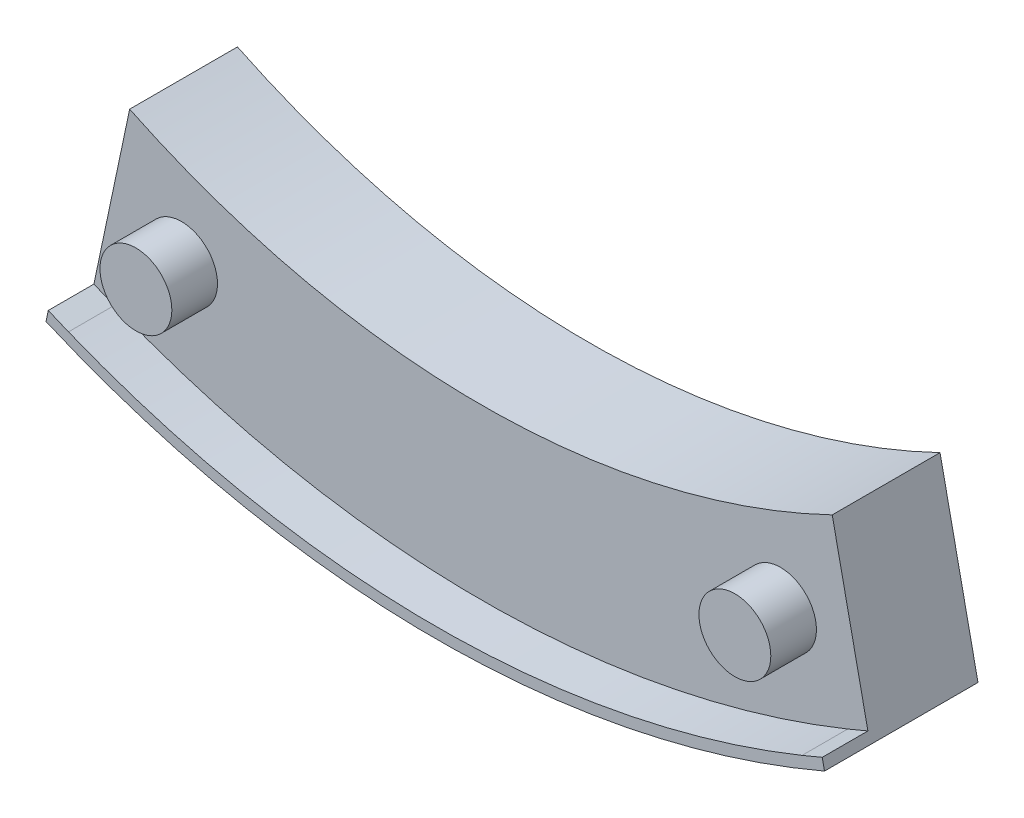
from build123d import *

# Parameters (mm, degrees)
SKETCH1_R           = 1.999999943
BOSS_EXTRUDE1_DEPTH = 6
SKETCH1_3_R         = 1.999999943
BOSS_EXTRUDE2_DEPTH = 8.54


with BuildPart() as part:
    # Sketch1 → Boss-Extrude1 (new body)
    with BuildSketch(Plane.XY):
        with BuildLine():
            Line((-19.553972123, -40.529522255), (-21.543248991, -49.954902644))
            Line((-21.543248991, -49.954902644), (-20.41822196, -50.425046499))
            ThreePointArc((-20.41822196, -50.425046499), (-10.404121129, -53.396800588), (-0.006635132, -54.399707743))
            ThreePointArc((-0.006635132, -54.399707743), (10.39066306, -53.396824107), (20.404594428, -50.42516399))
            Line((20.404594428, -50.42516399), (21.529621459, -49.955020135))
            Line((21.529621459, -49.955020135), (19.54391785, -40.534371527))
            ThreePointArc((19.54391785, -40.534371527), (-0.005581304, -44.999999654), (-19.553972123, -40.529522255))
        make_face()
        with Locations((-16.665975394, -46.501988883)):
            Circle(SKETCH1_R, mode=Mode.SUBTRACT)
        with Locations((16.665975394, -46.501988883)):
            Circle(SKETCH1_R, mode=Mode.SUBTRACT)
    extrude(amount=BOSS_EXTRUDE1_DEPTH)

    # Sketch1_3 → Boss-Extrude2 (add)
    with BuildSketch(Plane.XY):
        with BuildLine():
            Line((-20.41822196, -50.425046499), (-21.543248991, -49.954902644))
            Line((-21.543248991, -49.954902644), (-21.669150988, -50.551438115))
            ThreePointArc((-21.669150988, -50.551438115), (-0.006892589, -54.999999568), (21.656480116, -50.556867674))
            Line((21.656480116, -50.556867674), (21.529621459, -49.955020135))
            Line((21.529621459, -49.955020135), (20.404594428, -50.42516399))
            ThreePointArc((20.404594428, -50.42516399), (-0.006825205, -54.399707743), (-20.41822196, -50.425046499))
        make_face()
        with Locations((16.665975394, -46.501988883)):
            Circle(SKETCH1_3_R)
        with Locations((-16.665975394, -46.501988883)):
            Circle(SKETCH1_3_R)
    extrude(amount=BOSS_EXTRUDE2_DEPTH)


solid = part.part
